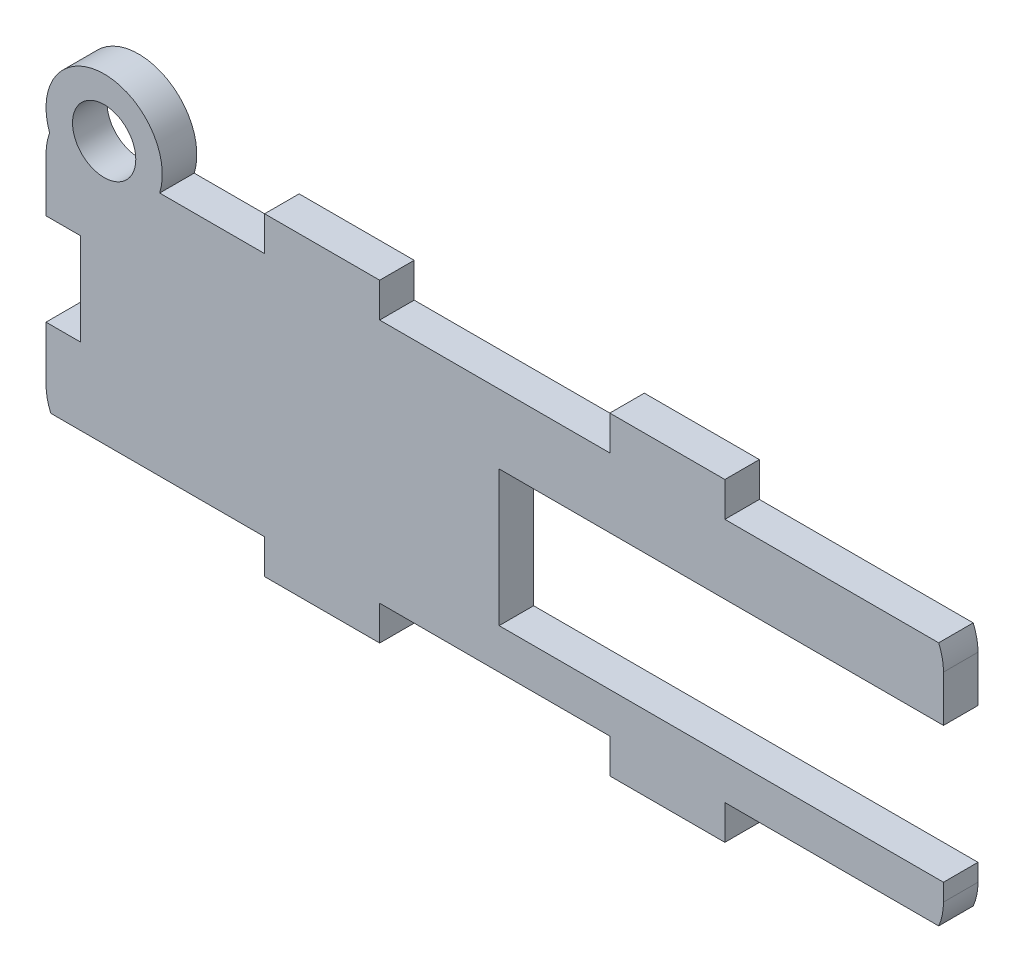
from build123d import *

# Parameters (mm, degrees)
BOSS_EXTRUDE1_DEPTH = 3
CUT_EXTRUDE1_REACH  = 5
SKETCH3_R           = 5.053902861
SKETCH3_R_2         = 2.75
BOSS_EXTRUDE2_DEPTH = 3
CUT_EXTRUDE2_REACH  = 5
SKETCH5_W           = 3
SKETCH5_H           = 8
CUT_EXTRUDE3_DEPTH  = 3


with BuildPart() as part:
    # Sketch1 → Boss-Extrude1 (new body)
    with BuildSketch(Plane.XY):
        with BuildLine():
            Line((-7, -3), (3, -3))
            Line((3, -3), (3, 0))
            Line((3, 0), (23, 0))
            Line((23, 0), (23, -3))
            Line((23, -3), (33, -3))
            Line((33, -3), (33, 0))
            Line((33, 0), (51.582575695, 0))
            ThreePointArc((51.582575695, 0), (51.894531565, 0.978451782), (52, 2))
            Line((52, 2), (52, 19.311841589))
            ThreePointArc((52, 19.311841589), (51.894531565, 20.333389808), (51.582575695, 21.311841589))
            Line((51.582575695, 21.311841589), (33, 21.311841589))
            Line((33, 21.311841589), (33, 24.311841589))
            Line((33, 24.311841589), (23, 24.311841589))
            Line((23, 24.311841589), (23, 21.311841589))
            Line((23, 21.311841589), (3, 21.311841589))
            Line((3, 21.311841589), (3, 24.311841589))
            Line((3, 24.311841589), (-7, 24.311841589))
            Line((-7, 24.311841589), (-7, 21.311841589))
            Line((-7, 21.311841589), (-25.582575695, 21.311841589))
            ThreePointArc((-25.582575695, 21.311841589), (-25.894531565, 20.333389808), (-26, 19.311841589))
            Line((-26, 19.311841589), (-26, 2))
            ThreePointArc((-26, 2), (-25.894531565, 0.978451782), (-25.582575695, 0))
            Line((-25.582575695, 0), (-7, 0))
            Line((-7, 0), (-7, -3))
        make_face()
    extrude(amount=BOSS_EXTRUDE1_DEPTH)

    # Sketch2 → Cut-Extrude1 (cut, up to next)
    with BuildSketch(Plane.XY.offset(3), mode=Mode.PRIVATE) as cut_extrude1_sk1:
        Polygon((13.38, 3.5), (13.38, 15.3), (23.54, 15.3), (52, 15.3), (52, 3.5), align=None)
    cut_extrude1_tool1 = extrude(cut_extrude1_sk1.sketch, amount=-CUT_EXTRUDE1_REACH, mode=Mode.PRIVATE) & part.part
    add(cut_extrude1_tool1.solids().sort_by_distance((32.69, 9.4, 3))[0], mode=Mode.SUBTRACT)

    # Sketch3 → Boss-Extrude2 (add)
    with BuildSketch(Plane.XY.offset(3)):
        with Locations((-20.946097139, 22.811841589)):
            Circle(SKETCH3_R)
        with Locations((-20.946097139, 22.811841589)):
            Circle(SKETCH3_R_2, mode=Mode.SUBTRACT)
    extrude(amount=-BOSS_EXTRUDE2_DEPTH)

    # Sketch4 → Cut-Extrude2 (cut, up to next)
    with BuildSketch(Plane.XY.offset(3), mode=Mode.PRIVATE) as cut_extrude2_sk1:
        with BuildLine():
            Line((-23.250983253, 21.311841589), (-18.641211025, 21.311841589))
            ThreePointArc((-18.641211025, 21.311841589), (-20.946097139, 20.061841589), (-23.250983253, 21.311841589))
        make_face()
    cut_extrude2_tool1 = extrude(cut_extrude2_sk1.sketch, amount=-CUT_EXTRUDE2_REACH, mode=Mode.PRIVATE) & part.part
    add(cut_extrude2_tool1.solids().sort_by_distance((-20.946097, 20.800609, 3))[0], mode=Mode.SUBTRACT)

    # Sketch5 → Cut-Extrude3 (cut)
    with BuildSketch(Plane.XY.offset(3)):
        with Locations((-24.5, 10.655920795)):
            Rectangle(SKETCH5_W, SKETCH5_H)
    extrude(amount=-CUT_EXTRUDE3_DEPTH, mode=Mode.SUBTRACT)


solid = part.part
